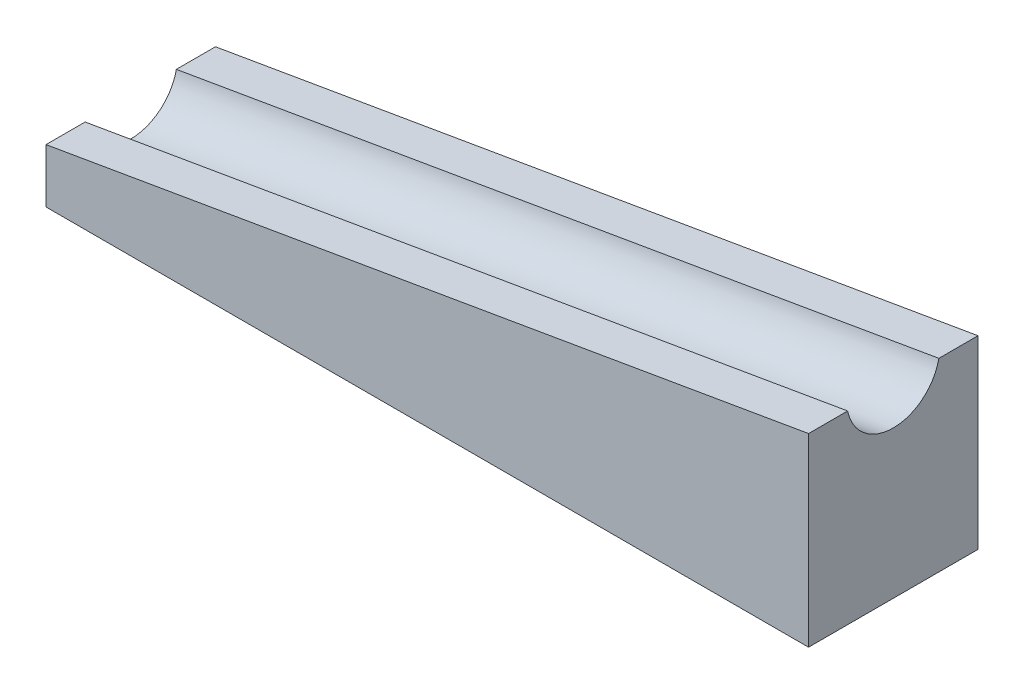
from build123d import *

# Parameters (mm, degrees)
BOSS_EXTRUDE1_DEPTH = 20
CUT_EXTRUDE1_DEPTH  = 93.39919136


with BuildPart() as part:
    # Sketch2 → Boss-Extrude1 (new body)
    with BuildSketch(Plane.XY):
        Polygon((90, 0), (90, 15.464828415), (0, 0), (0, -6.378436315), (90, -6.378436315), align=None)
    extrude(amount=BOSS_EXTRUDE1_DEPTH)

    # Sketch5 → Cut-Extrude1 (cut, through all)
    with BuildSketch(Plane(origin=(90, 15.464828415, 0), x_dir=(0, 0, -1), z_dir=(0.985556059, 0.169349504, 0))):
        with BuildLine():
            Line((-15.381941787, 0), (-4.618058213, 0))
            ThreePointArc((-4.618058213, 0), (-10, -4.366552781), (-15.381941787, 0))
        make_face()
    extrude(amount=-CUT_EXTRUDE1_DEPTH, mode=Mode.SUBTRACT)


solid = part.part
